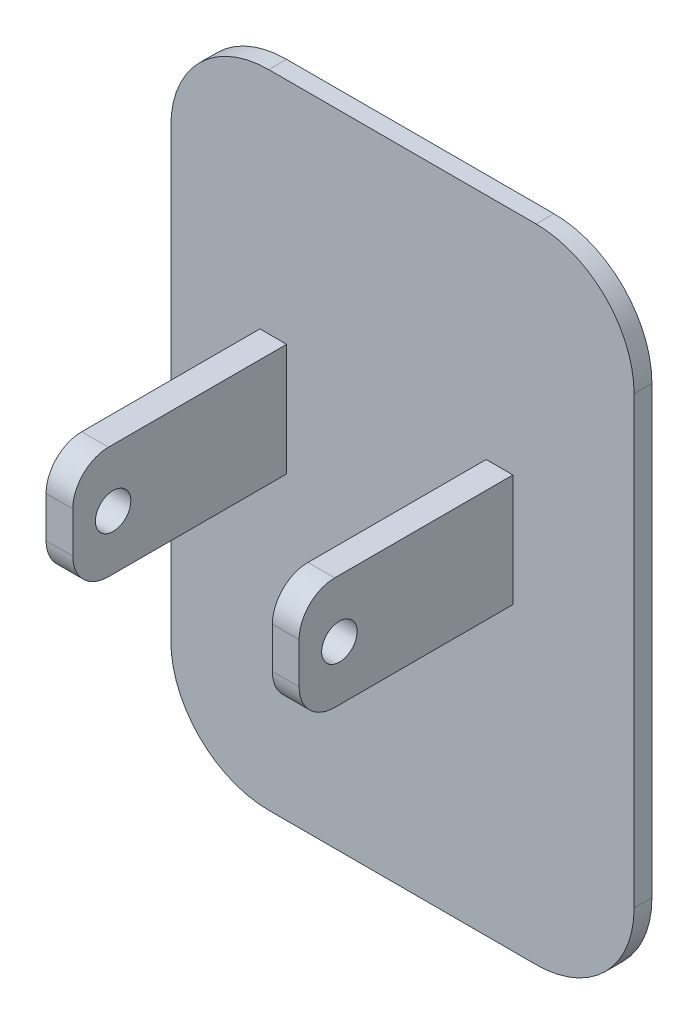
from build123d import *

# Parameters (mm, degrees)
SKETCH1_W             = 1.5
SKETCH1_H             = 6.3
BOSS_EXTRUDE1_DEPTH   = 1
SKETCH2_W             = 1.5
SKETCH2_H             = 6.3
BOSS_EXTRUDE2_DEPTH   = 12
BOSS_EXTRUDE2_2_DEPTH = 12
SKETCH3_R             = 0.994767201
CUT_EXTRUDE1_DEPTH    = 20.2
FILLET1_R             = 2
FILLET2_R             = 2


with BuildPart() as part:
    # Sketch1 → Boss-Extrude1 (new body)
    with BuildSketch(Plane.XY):
        with BuildLine():
            Line((13.9, -10.637455146), (13.9, 14.362544854))
            ThreePointArc((13.9, 14.362544854), (12.289087297, 18.251632151), (8.4, 19.862544854))
            Line((8.4, 19.862544854), (-6.6, 19.862544854))
            ThreePointArc((-6.6, 19.862544854), (-10.489087297, 18.251632151), (-12.1, 14.362544854))
            Line((-12.1, 14.362544854), (-12.1, -10.637455146))
            ThreePointArc((-12.1, -10.637455146), (-10.489087297, -14.526542442), (-6.6, -16.137455146))
            Line((-6.6, -16.137455146), (8.4, -16.137455146))
            ThreePointArc((8.4, -16.137455146), (12.289087297, -14.526542442), (13.9, -10.637455146))
        make_face()
        with Locations((-6.35, 3.863496204)):
            Rectangle(SKETCH1_W, SKETCH1_H, mode=Mode.SUBTRACT)
        with Locations((6.35, 3.863496204)):
            Rectangle(SKETCH1_W, SKETCH1_H, mode=Mode.SUBTRACT)
    extrude(amount=BOSS_EXTRUDE1_DEPTH)


with BuildPart() as body_2:
    # Sketch2 → Boss-Extrude2 (new body)
    with BuildSketch(Plane.XY.offset(1)):
        with Locations((-6.35, 3.863496204)):
            Rectangle(SKETCH2_W, SKETCH2_H)
    extrude(amount=BOSS_EXTRUDE2_DEPTH)


with BuildPart() as body_3:
    # Sketch2 → Boss-Extrude2 2 (new body)
    with BuildSketch(Plane.XY.offset(1)):
        with Locations((6.35, 3.863496204)):
            Rectangle(SKETCH2_W, SKETCH2_H)
    extrude(amount=BOSS_EXTRUDE2_2_DEPTH)


with BuildPart() as cut_extrude1_tool:
    # Sketch3 → Cut-Extrude1 (new body, through all)
    with BuildSketch(Plane(origin=(7.1, 0, 0), x_dir=(0, 0, -1), z_dir=(1, 0, 0))):
        with Locations((-10.739603072, 3.781024457)):
            Circle(SKETCH3_R)
    extrude(amount=-CUT_EXTRUDE1_DEPTH)


with BuildPart() as body_2_1:
    add(body_2.part)

    # Cut-Extrude1: cut by cut_extrude1_tool
    add(cut_extrude1_tool.part, mode=Mode.SUBTRACT)

    # Fillet2
    fillet2_edges = [body_2_1.edges().sort_by_distance(p)[0] for p in [
        (-6.35, 7.013496204, 13),
        (-6.35, 0.713496204, 13),
    ]]
    fillet(fillet2_edges, radius=FILLET2_R)


with BuildPart() as body_3_1:
    add(body_3.part)

    # Cut-Extrude1: cut by cut_extrude1_tool
    add(cut_extrude1_tool.part, mode=Mode.SUBTRACT)

    # Fillet1
    fillet1_edges = [body_3_1.edges().sort_by_distance(p)[0] for p in [
        (6.35, 0.713496204, 13),
        (6.35, 7.013496204, 13),
    ]]
    fillet(fillet1_edges, radius=FILLET1_R)


solid = Compound([part.part, body_2_1.part, body_3_1.part])
